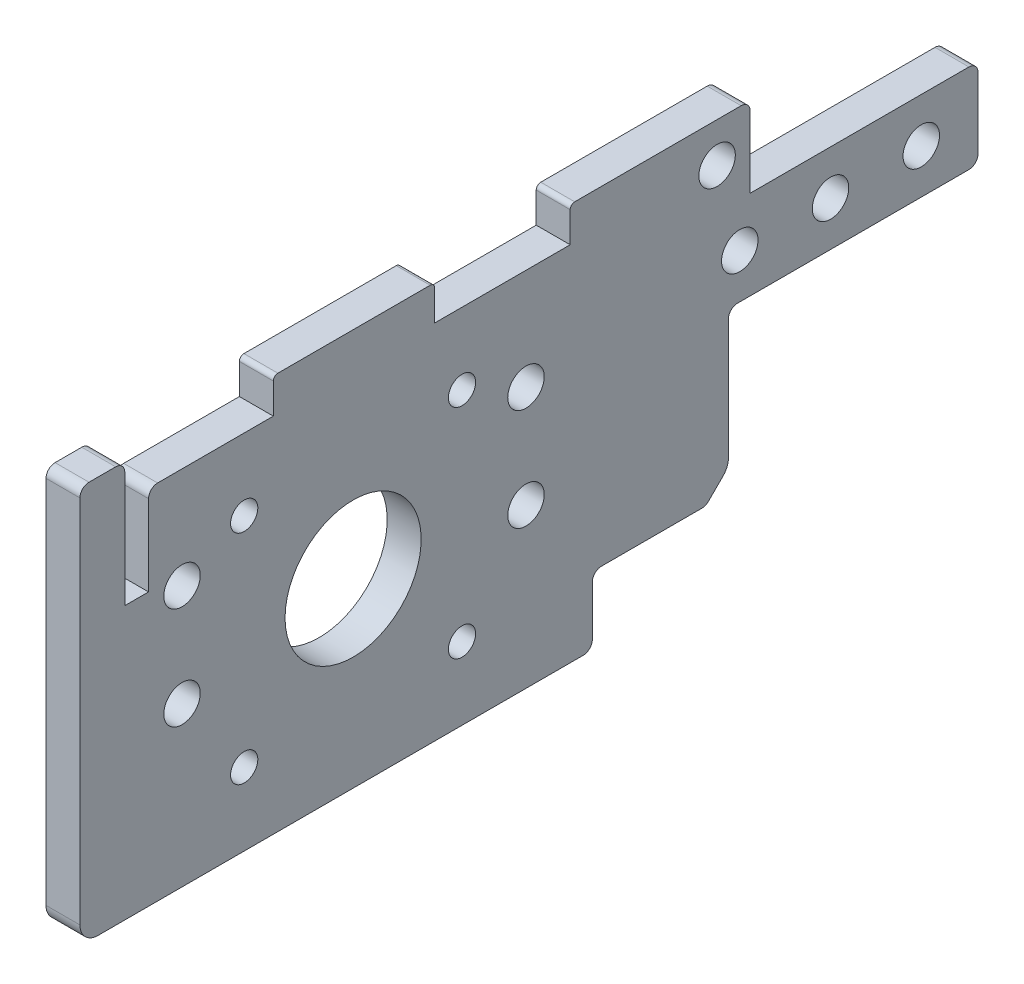
from build123d import *

# Parameters (mm, degrees)
SKETCH6_R                   = 9.525
SKETCH6_R_2                 = 1.905
SKETCH6_R_3                 = 2.5527
SIDE_PLATE_EXTRUDE_DEPTH    = 4.7498
SKETCH15_R                  = 2.5527
CUSTOM_NUTSTRIP_HOLES_DEPTH = 5.7498
SKETCH43_W                  = 3.175
SKETCH43_H                  = 12.7
CUT_EXTRUDE19_DEPTH         = 5.7498
SKETCH73_W                  = 15.875
SKETCH73_H                  = 4.7625
SKETCH73_W_2                = 22.733
SKETCH73_W_3                = 6.35
BOSS_EXTRUDE28_DEPTH        = 4.7498
SKETCH108_W                 = 9.525
SKETCH108_H                 = 11.1125
SKETCH108_R                 = 2.5527
BOSS_EXTRUDE35_DEPTH        = 4.7498
SKETCH90_W                  = 18.959213894
SKETCH90_H                  = 4.8895
SKETCH90_W_2                = 34.925
SKETCH90_H_2                = 31.877
SIDE_PLATE_TOLERENCES_DEPTH = 5.7498
CHAMFER8_SIZE               = 12.7
FILLET15_R                  = 2.54
FILLET26_R                  = 1.27
FILLET29_R                  = 0.635
SKETCH109_W                 = 19.05
SKETCH109_H                 = 9.525
CUT_EXTRUDE20_DEPTH         = 5.7498
FILLET30_R                  = 1.27


with BuildPart() as part:
    # Sketch6 → Side Plate Extrude (new body)
    with BuildSketch(Plane.ZY.offset(104.775)):
        Polygon((162.052, -25.4), (162.052, 25.4), (77.649686106, 25.4), (77.649686106, 19.05), (36.374686106, 19.05), (36.374686106, 6.35), (71.299686106, 6.35), (71.299686106, -25.4), align=None)
        with Locations((123.825, 0)):
            Circle(SKETCH6_R, mode=Mode.SUBTRACT)
        with Locations((108.585, -15.24)):
            Circle(SKETCH6_R_2, mode=Mode.SUBTRACT)
        with Locations((108.585, 15.24)):
            Circle(SKETCH6_R_2, mode=Mode.SUBTRACT)
        with Locations((139.065, 15.24)):
            Circle(SKETCH6_R_2, mode=Mode.SUBTRACT)
        with Locations((139.065, -15.24)):
            Circle(SKETCH6_R_2, mode=Mode.SUBTRACT)
        with Locations((147.7645, 11.1125)):
            Circle(SKETCH6_R_3, mode=Mode.SUBTRACT)
        with Locations((99.6315, 11.1125)):
            Circle(SKETCH6_R_3, mode=Mode.SUBTRACT)
        with Locations((99.6315, -3.175)):
            Circle(SKETCH6_R_3, mode=Mode.SUBTRACT)
        with Locations((147.7645, -3.175)):
            Circle(SKETCH6_R_3, mode=Mode.SUBTRACT)
    extrude(amount=SIDE_PLATE_EXTRUDE_DEPTH)

    # Sketch15 → Custom Nutstrip Holes (cut, through all)
    with BuildSketch(Plane.ZY.offset(109.5248)):
        with Locations((44.312186106, 12.7)):
            Circle(SKETCH15_R)
        with Locations((57.012186106, 12.7)):
            Circle(SKETCH15_R)
        with Locations((69.712186106, 12.7)):
            Circle(SKETCH15_R)
    extrude(amount=-CUSTOM_NUTSTRIP_HOLES_DEPTH, mode=Mode.SUBTRACT)

    # Sketch43 → Cut-Extrude19 (cut, through all)
    with BuildSketch(Plane.ZY.offset(109.5248)):
        with Locations((154.1145, 19.05)):
            Rectangle(SKETCH43_W, SKETCH43_H)
    extrude(amount=-CUT_EXTRUDE19_DEPTH, mode=Mode.SUBTRACT)

    # Sketch73 → Boss-Extrude28 (add, through all)
    with BuildSketch(Plane.ZY.offset(109.5248)):
        with Locations((85.587186106, 27.78125)):
            Rectangle(SKETCH73_W, SKETCH73_H)
        with Locations((123.698, 27.78125)):
            Rectangle(SKETCH73_W_2, SKETCH73_H)
        with Locations((158.877, 27.78125)):
            Rectangle(SKETCH73_W_3, SKETCH73_H)
    extrude(amount=-BOSS_EXTRUDE28_DEPTH)

    # Sketch108 → Boss-Extrude35 (add, through all)
    with BuildSketch(Plane(origin=(-104.775, 0, 0), x_dir=(0, 0, -1), z_dir=(1, 0, 0))):
        with Locations((-72.887186106, 24.60625)):
            Rectangle(SKETCH108_W, SKETCH108_H)
        with Locations((-72.887186106, 24.60625)):
            Circle(SKETCH108_R, mode=Mode.SUBTRACT)
    extrude(amount=-BOSS_EXTRUDE35_DEPTH)

    # Sketch90 → Side Plate Tolerences (cut, through all)
    with BuildSketch(Plane(origin=(-104.775, 0, 0), x_dir=(0, 0, -1), z_dir=(1, 0, 0))):
        Polygon((-152.4508, 12.7), (-155.7782, 12.7), (-155.7782, 30.1625), (-152.4508, 30.1625), (-134.9883, 30.1625), (-134.9883, 25.273), (-152.4508, 25.273), align=None)
        with Locations((-102.928093053, 27.71775)):
            Rectangle(SKETCH90_W, SKETCH90_H)
        Polygon((-68.124686106, 19.05), (-36.374686106, 19.05), (-36.374686106, 18.923), (-68.124686106, 18.923), (-68.251686106, 18.923), (-68.251686106, 30.1625), (-68.124686106, 30.1625), align=None)
        with Locations((-53.837186106, -9.4615)):
            Rectangle(SKETCH90_W_2, SKETCH90_H_2)
    extrude(amount=-SIDE_PLATE_TOLERENCES_DEPTH, mode=Mode.SUBTRACT)

    # Chamfer8
    chamfer8_edges = [part.edges().sort_by_distance(p)[0] for p in [
        (-107.1499, -25.4, 71.299686106),
    ]]
    chamfer(chamfer8_edges, length=CHAMFER8_SIZE)

    # Fillet15
    fillet15_edges = [part.edges().sort_by_distance(p)[0] for p in [
        (-107.1499, -25.4, 162.052),
        (-107.1499, -25.4, 83.999686106),
        (-107.1499, -12.7, 71.299686106),
    ]]
    fillet(fillet15_edges, radius=FILLET15_R)

    # Fillet26
    fillet26_edges = [part.edges().sort_by_distance(p)[0] for p in [
        (-107.1499, 30.1625, 162.052),
        (-107.1499, 30.1625, 155.7782),
        (-107.1499, 25.273, 152.4508),
        (-107.1499, 18.923, 36.374686106),
        (-107.1499, 30.1625, 68.251686106),
        (-107.1499, 6.477, 36.374686106),
        (-107.1499, 6.477, 71.299686106),
    ]]
    fillet(fillet26_edges, radius=FILLET26_R)

    # Fillet29
    fillet29_edges = [part.edges().sort_by_distance(p)[0] for p in [
        (-107.1499, 30.1625, 134.9883),
        (-107.1499, 30.1625, 112.4077),
        (-107.1499, 30.1625, 93.448486106),
    ]]
    fillet(fillet29_edges, radius=FILLET29_R)

    # Sketch109 → Cut-Extrude20 (cut, through all)
    with BuildSketch(Plane(origin=(-104.775, 0, 0), x_dir=(0, 0, -1), z_dir=(1, 0, 0))):
        with Locations((-80.824686106, -20.6375)):
            Rectangle(SKETCH109_W, SKETCH109_H)
    extrude(amount=-CUT_EXTRUDE20_DEPTH, mode=Mode.SUBTRACT)

    # Fillet30
    fillet30_edges = [part.edges().sort_by_distance(p)[0] for p in [
        (-107.1499, -15.875, 74.474686106),
        (-107.1499, -25.4, 90.349686106),
        (-107.1499, -15.875, 90.349686106),
    ]]
    fillet(fillet30_edges, radius=FILLET30_R)


solid = part.part
